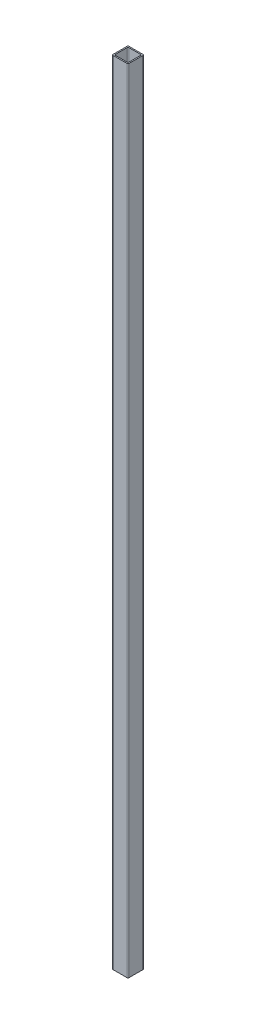
from build123d import *

# Parameters (mm, degrees)
BOSS_EXTRUDE1_DEPTH = 1000


with BuildPart() as part:
    # Sketch1 → Boss-Extrude1 (new body)
    with BuildSketch(Plane(origin=(0, 0, 0), x_dir=(1, 0, 0), z_dir=(0, 1, 0))):
        with BuildLine():
            Line((-9, -10), (9, -10))
            ThreePointArc((9, -10), (9.707106781, -9.707106781), (10, -9))
            Line((10, -9), (10, 9))
            ThreePointArc((10, 9), (9.707106781, 9.707106781), (9, 10))
            Line((9, 10), (-9, 10))
            ThreePointArc((-9, 10), (-9.707106781, 9.707106781), (-10, 9))
            Line((-10, 9), (-10, -9))
            ThreePointArc((-10, -9), (-9.707106781, -9.707106781), (-9, -10))
        make_face()
        with BuildLine():
            Line((-7.5, -8.5), (7.5, -8.5))
            ThreePointArc((7.5, -8.5), (8.207106781, -8.207106781), (8.5, -7.5))
            Line((8.5, -7.5), (8.5, 7.5))
            ThreePointArc((8.5, 7.5), (8.207106781, 8.207106781), (7.5, 8.5))
            Line((7.5, 8.5), (-7.5, 8.5))
            ThreePointArc((-7.5, 8.5), (-8.207106781, 8.207106781), (-8.5, 7.5))
            Line((-8.5, 7.5), (-8.5, -7.5))
            ThreePointArc((-8.5, -7.5), (-8.207106781, -8.207106781), (-7.5, -8.5))
        make_face(mode=Mode.SUBTRACT)
    extrude(amount=BOSS_EXTRUDE1_DEPTH)


solid = part.part
